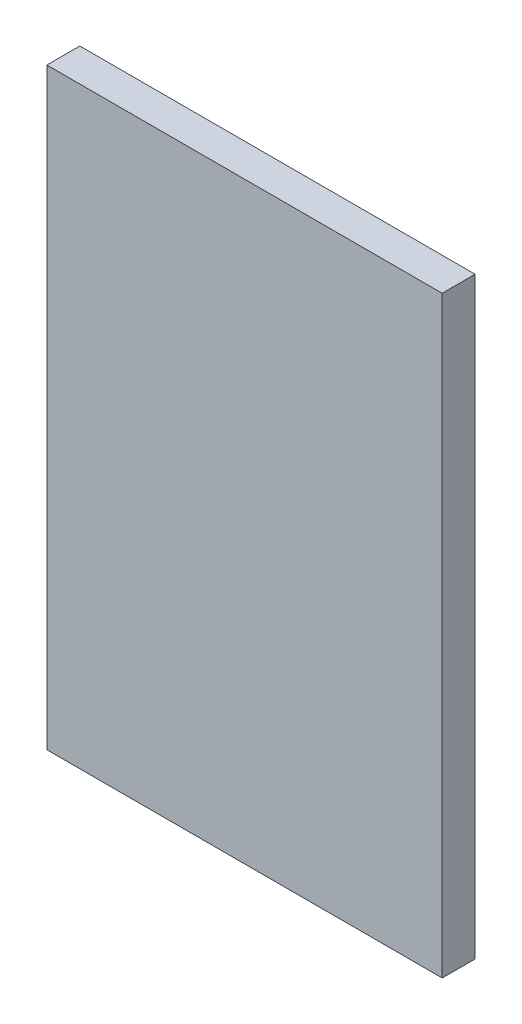
from build123d import *

# Parameters (mm, degrees)
CROQUIS1_W              = 60
CROQUIS1_H              = 90
SALIENTE_EXTRUIR1_DEPTH = 5


with BuildPart() as part:
    # Croquis1 → Saliente-Extruir1 (new body)
    with BuildSketch(Plane.XY):
        Rectangle(CROQUIS1_W, CROQUIS1_H)
    extrude(amount=SALIENTE_EXTRUIR1_DEPTH)


solid = part.part
